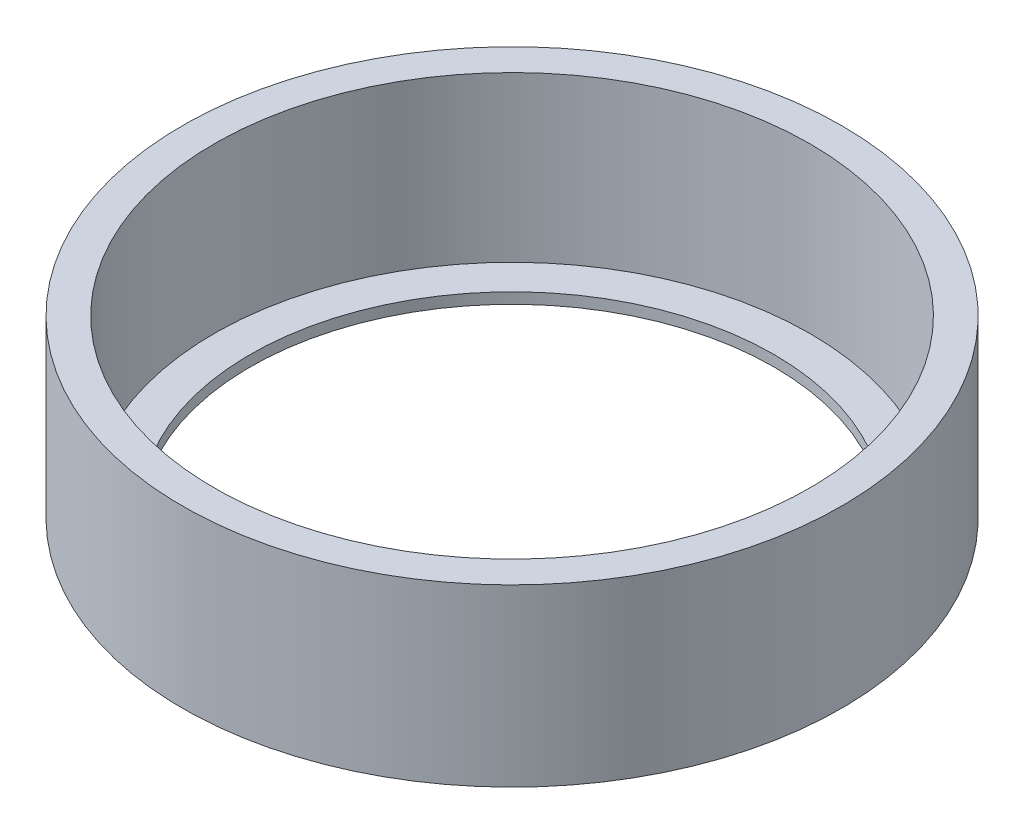
from build123d import *


with BuildPart() as part:
    # Sketch1 → Revolve1 (revolve)
    with BuildSketch(Plane.XY):
        Polygon((46.355, 0), (46.355, 24.638), (41.91, 24.638), (41.91, 1.524), (36.83, 1.524), (36.83, 0), align=None)
    revolve(axis=Axis((0, 0, 0), (0, 1, 0)))


solid = part.part
